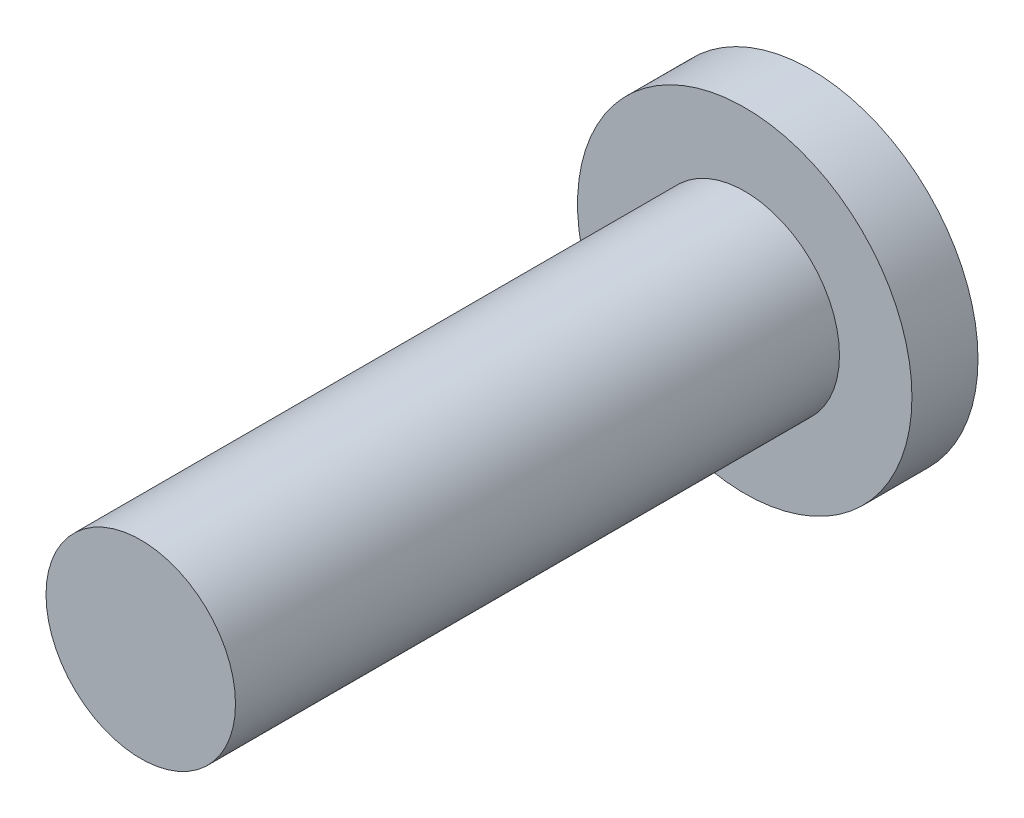
from build123d import *

# Parameters (mm, degrees)
SKETCH1_R           = 4.5
BOSS_EXTRUDE2_DEPTH = 1.778
SKETCH2_R           = 2.55
BOSS_EXTRUDE4_DEPTH = 16.256


with BuildPart() as part:
    # Sketch1 → Boss-Extrude2 (new body)
    with BuildSketch(Plane.XY):
        with Locations((-10.060269198, 7.746407282)):
            Circle(SKETCH1_R)
    extrude(amount=BOSS_EXTRUDE2_DEPTH)

    # Sketch2 → Boss-Extrude4 (add)
    with BuildSketch(Plane.XY.offset(1.778)):
        with Locations((-10.060269198, 7.746407282)):
            Circle(SKETCH2_R)
    extrude(amount=BOSS_EXTRUDE4_DEPTH)


solid = part.part
